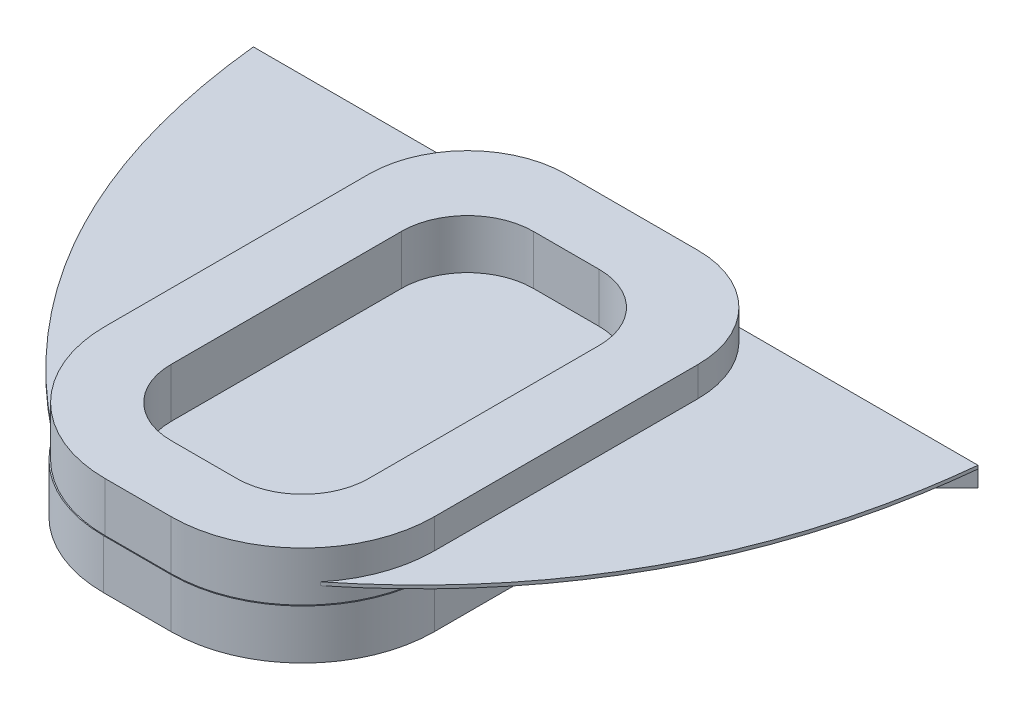
from build123d import *

# Parameters (mm, degrees)
EXTRUDE_1_DEPTH = 3
SKETCH_2_W      = 2
SKETCH_2_H      = 22
EXTRUDE_2_DEPTH = 1
EXTRUDE_3_DEPTH = 0.2
EXTRUDE_4_DEPTH = 3
SCALE_1_SCALE   = 0.1


with BuildPart() as part:
    # 草图1 → 凸台-拉伸1 (new body)
    with BuildSketch(Plane(origin=(0, 0, 0), x_dir=(1, 0, 0), z_dir=(0, 1, 0))):
        with BuildLine():
            Line((-4.05, 15.05), (4.05, 15.05))
            ThreePointArc((4.05, 15.05), (8.292640687, 13.292640687), (10.05, 9.05))
            Line((10.05, 9.05), (10.05, -7.05))
            ThreePointArc((10.05, -7.05), (7.706854249, -12.706854249), (2.05, -15.05))
            Line((2.05, -15.05), (-2.05, -15.05))
            ThreePointArc((-2.05, -15.05), (-7.706854249, -12.706854249), (-10.05, -7.05))
            Line((-10.05, -7.05), (-10.05, 9.05))
            ThreePointArc((-10.05, 9.05), (-8.292640687, 13.292640687), (-4.05, 15.05))
        make_face()
    extrude(amount=EXTRUDE_1_DEPTH)

    # 草图2 → 凸台-拉伸2 (add)
    with BuildSketch(Plane(origin=(0, 3, 0), x_dir=(1, 0, 0), z_dir=(0, 1, 0))):
        with Locations((-8, 1)):
            Rectangle(SKETCH_2_W, SKETCH_2_H)
        with BuildLine():
            Line((-9, 12), (-7, 12))
            Line((-7, 12), (-2, 12))
            Line((-2, 12), (-2, 14))
            Line((-2, 14), (-7.440796367, 14))
            ThreePointArc((-7.440796367, 14), (-8.472295614, 13.105034094), (-9.274700948, 12))
            Line((-9.274700948, 12), (-9, 12))
        make_face()
        with BuildLine():
            Line((-20, 12), (-9.274700948, 12))
            ThreePointArc((-9.274700948, 12), (-8.472295614, 13.105034094), (-7.440796367, 14))
            Line((-7.440796367, 14), (-20, 14))
            Line((-20, 14), (-20, 12))
        make_face()
        Polygon((-20, 14), (-22, 14), (-20, 12), align=None)
        Polygon((-7, -13), (-9, -10), (-7, -10), align=None)
        with BuildLine():
            ThreePointArc((9.274700948, 12), (8.472295614, 13.105034094), (7.440796367, 14))
            Line((7.440796367, 14), (2, 14))
            Line((2, 14), (2, 12))
            Line((2, 12), (7, 12))
            Line((7, 12), (9, 12))
            Line((9, 12), (9.274700948, 12))
        make_face()
        with BuildLine():
            Line((20, 12), (20, 14))
            Line((20, 14), (7.440796367, 14))
            ThreePointArc((7.440796367, 14), (8.472295614, 13.105034094), (9.274700948, 12))
            Line((9.274700948, 12), (20, 12))
        make_face()
        Polygon((20, 12), (20, 14), (22, 14), align=None)
        with Locations((8, 1)):
            Rectangle(SKETCH_2_W, SKETCH_2_H)
        Polygon((7, -10), (9, -10), (7, -13), align=None)
    extrude(amount=EXTRUDE_2_DEPTH)

    # 草图3 → 凸台-拉伸3 (add)
    with BuildSketch(Plane(origin=(0, 4, 0), x_dir=(1, 0, 0), z_dir=(0, 1, 0))):
        with BuildLine():
            Line((-7, -13), (-7, 14))
            Line((-7, 14), (-22, 14))
            add(Edge.make_bspline(
                [(-22, 14), (-20.203305703, -3.149159716), (-7, -13)],
                knots=[0, 0, 0, 1, 1, 1], degree=2))
        make_face()
        with BuildLine():
            Line((7, -13), (7, 14))
            Line((7, 14), (22, 14))
            add(Edge.make_bspline(
                [(22, 14), (20.203305703, -3.149159716), (7, -13)],
                knots=[0, 0, 0, 1, 1, 1], degree=2))
        make_face()
    extrude(amount=EXTRUDE_3_DEPTH)

    # 草图4 → 凸台-拉伸4 (add)
    with BuildSketch(Plane(origin=(0, 3, 0), x_dir=(1, 0, 0), z_dir=(0, 1, 0))):
        with BuildLine():
            Line((-4, 15), (4, 15))
            ThreePointArc((4, 15), (8.242640687, 13.242640687), (10, 9))
            Line((10, 9), (10, -7))
            ThreePointArc((10, -7), (7.656854249, -12.656854249), (2, -15))
            Line((2, -15), (-2, -15))
            ThreePointArc((-2, -15), (-7.656854249, -12.656854249), (-10, -7))
            Line((-10, -7), (-10, 9))
            ThreePointArc((-10, 9), (-8.242640687, 13.242640687), (-4, 15))
        make_face()
        with BuildLine():
            Line((-2, 11), (2, 11))
            ThreePointArc((2, 11), (4.828427125, 9.828427125), (6, 7))
            Line((6, 7), (6, -7))
            ThreePointArc((6, -7), (4.828427125, -9.828427125), (2, -11))
            Line((2, -11), (-2, -11))
            ThreePointArc((-2, -11), (-4.828427125, -9.828427125), (-6, -7))
            Line((-6, -7), (-6, 7))
            ThreePointArc((-6, 7), (-4.828427125, 9.828427125), (-2, 11))
        make_face(mode=Mode.SUBTRACT)
    extrude(amount=EXTRUDE_4_DEPTH)


with BuildPart() as part_1:
    # 缩放比例1: scaled about (0, 0, 0)
    add(part.part.scale(SCALE_1_SCALE))


solid = part_1.part
